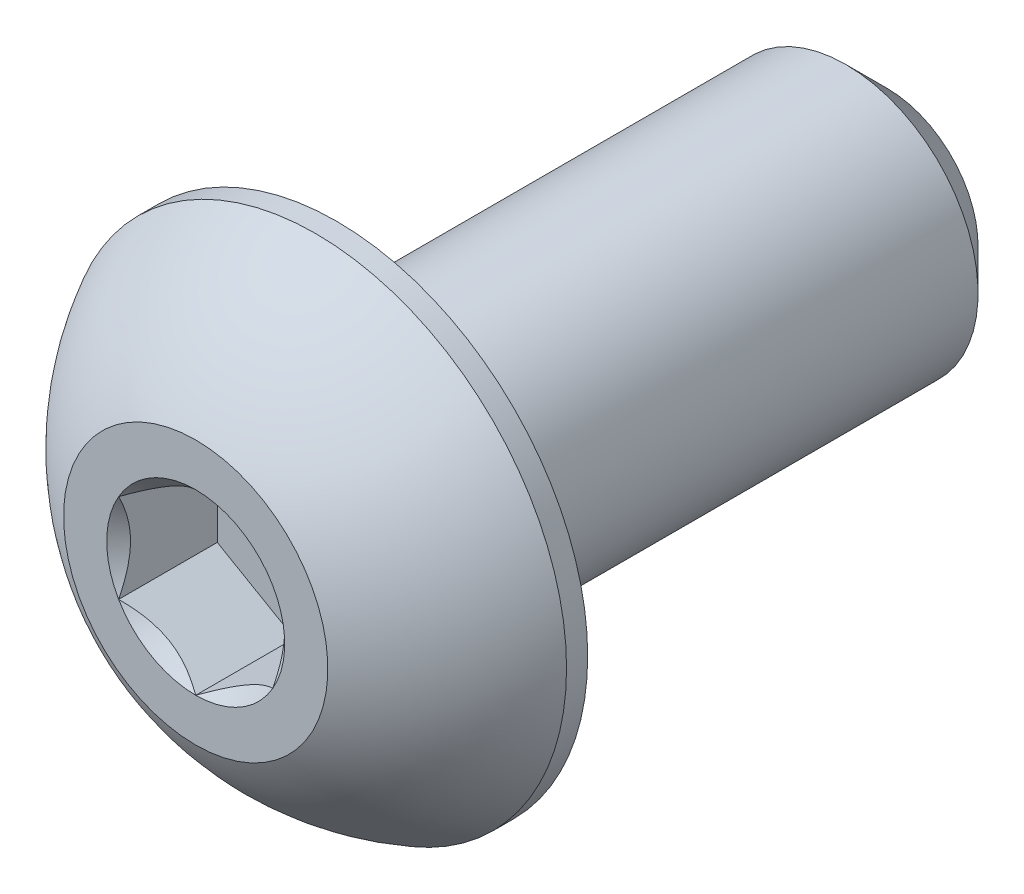
from build123d import *

# Parameters (mm, degrees)
SKETCH1_W          = 3.175
SKETCH1_H          = 0.762
CHAMFER1_SIZE      = 0.238125
CUT_EXTRUDE2_DEPTH = 0.56896


with BuildPart() as part:
    # Sketch1 → Revolve1 (revolve)
    with BuildSketch(Plane(origin=(0, 0, 0), x_dir=(0, 0, -1), z_dir=(1, 0, 0))):
        with Locations((2.4003, 0.381)):
            Rectangle(SKETCH1_W, SKETCH1_H)
    revolve(axis=Axis((0, 0, -3.9878), (0, 0, 1)))

    # Chamfer1
    chamfer1_edges = [part.edges().sort_by_distance(p)[0] for p in [
        (0, -0.762, -3.9878),
    ]]
    chamfer(chamfer1_edges, length=CHAMFER1_SIZE)

    # Sketch7 → Revolve2 (revolve)
    with BuildSketch(Plane(origin=(0, 0, 0), x_dir=(0, 0, -1), z_dir=(1, 0, 0))):
        with BuildLine():
            Line((0.69088, 1.4478), (0.8128, 1.4478))
            Line((0.8128, 1.4478), (0.8128, 0))
            Line((0.8128, 0), (0, 0))
            Line((0, 0), (0, 0.762))
            ThreePointArc((0, 0.762), (0.293086751, 1.157641051), (0.69088, 1.4478))
        make_face()
    revolve(axis=Axis((0, 0, 0), (0, 0, -1)))

    # Sketch5 → Cut-Extrude2 (cut)
    with BuildSketch(Plane.XY):
        Polygon((0.4445, -0.256632195), (0.4445, 0.256632195), (0, 0.513264389), (-0.4445, 0.256632195), (-0.4445, -0.256632195), (0, -0.513264389), align=None)
    extrude(amount=-CUT_EXTRUDE2_DEPTH, mode=Mode.SUBTRACT)

    # Cut-Extrude3 cone 1 section (through the dimple's axis) → Cut-Extrude3 (revolve, cut)
    with BuildSketch(Plane(origin=(0, 0, 0), x_dir=(0, -1, 0), z_dir=(1, 0, 0))):
        Polygon((0, 0), (0.513264389, 0), (0, 0.513264389), align=None)
    revolve(axis=Axis((0, 0, 0), (0, 0, -1)), mode=Mode.SUBTRACT)


solid = part.part
